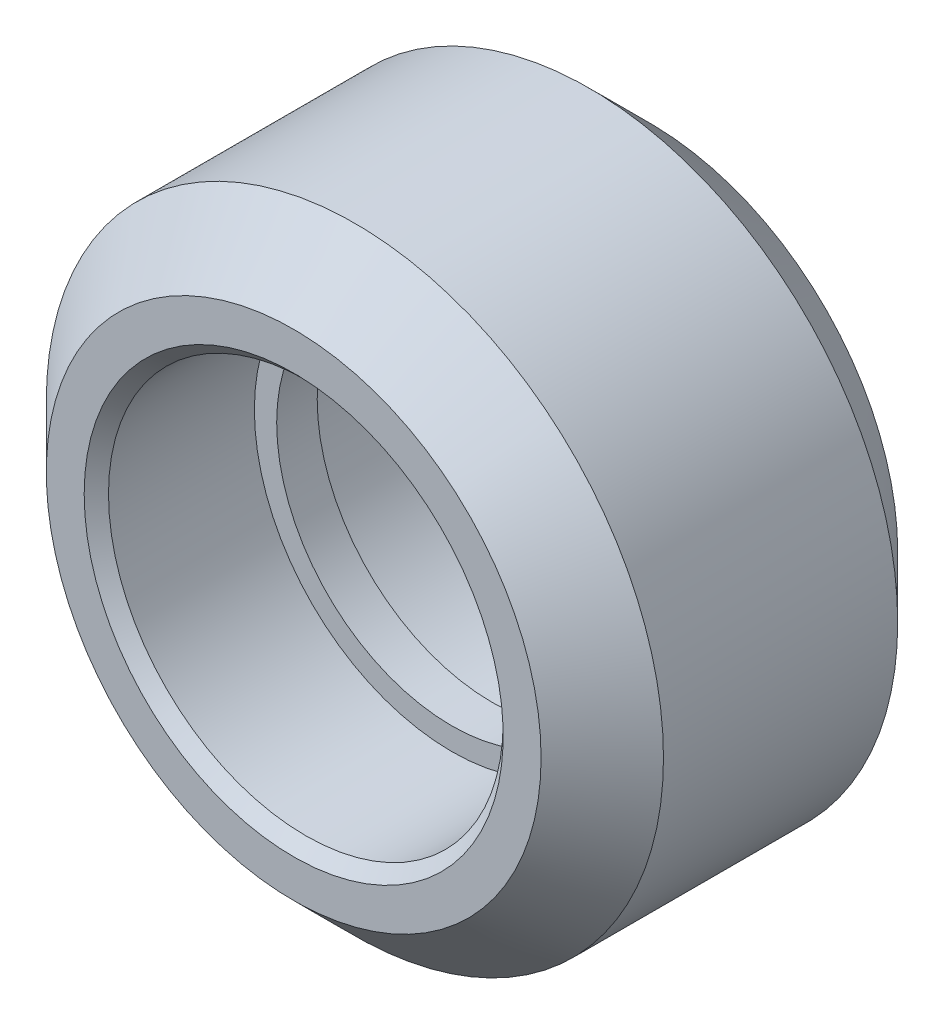
from build123d import *

# Parameters (mm, degrees)
CHAMFER1_SIZE = 0.3


with BuildPart() as part:
    # Sketch1 → Revolve1 (revolve)
    with BuildSketch(Plane(origin=(0, 0, 0), x_dir=(0, 0, -1), z_dir=(1, 0, 0))):
        Polygon((0.5, 4.32), (-0.5, 4.32), (-0.5, 4.87), (-4.4, 4.87), (-4.4, 6.105), (-2.89, 7.615), (2.89, 7.615), (4.4, 6.105), (4.4, 4.87), (0.5, 4.87), align=None)
    revolve(axis=Axis((0, 0, 0), (0, 0, -1)))

    # Chamfer1
    chamfer1_edges = [part.edges().sort_by_distance(p)[0] for p in [
        (0, -4.87, 4.4),
        (0, -4.87, -4.4),
    ]]
    chamfer(chamfer1_edges, length=CHAMFER1_SIZE)


solid = part.part
